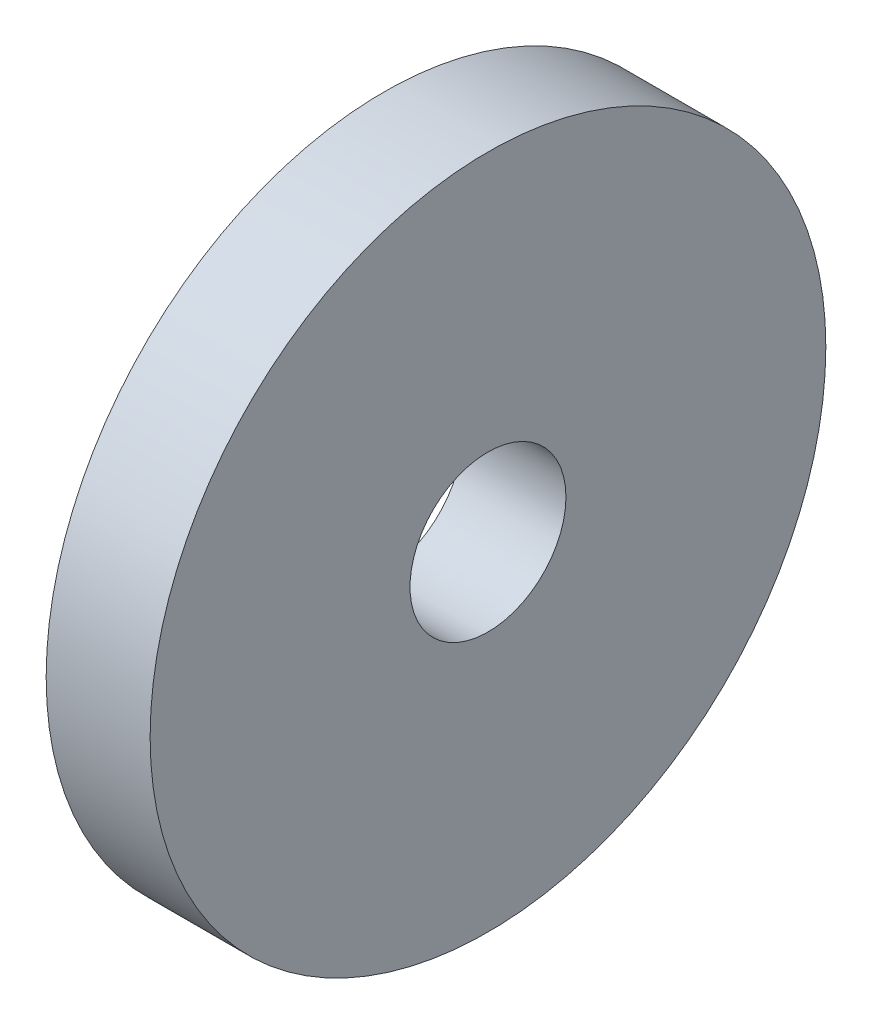
from build123d import *

# Parameters (mm, degrees)
CROQUIS1_R              = 6.5
CROQUIS1_R_2            = 1.5
SALIENTE_EXTRUIR1_DEPTH = 2


with BuildPart() as part:
    # Croquis1 → Saliente-Extruir1 (new body)
    with BuildSketch(Plane(origin=(0, 0, 0), x_dir=(0, 0, -1), z_dir=(1, 0, 0))):
        Circle(CROQUIS1_R)
        Circle(CROQUIS1_R_2, mode=Mode.SUBTRACT)
    extrude(amount=SALIENTE_EXTRUIR1_DEPTH)


solid = part.part
